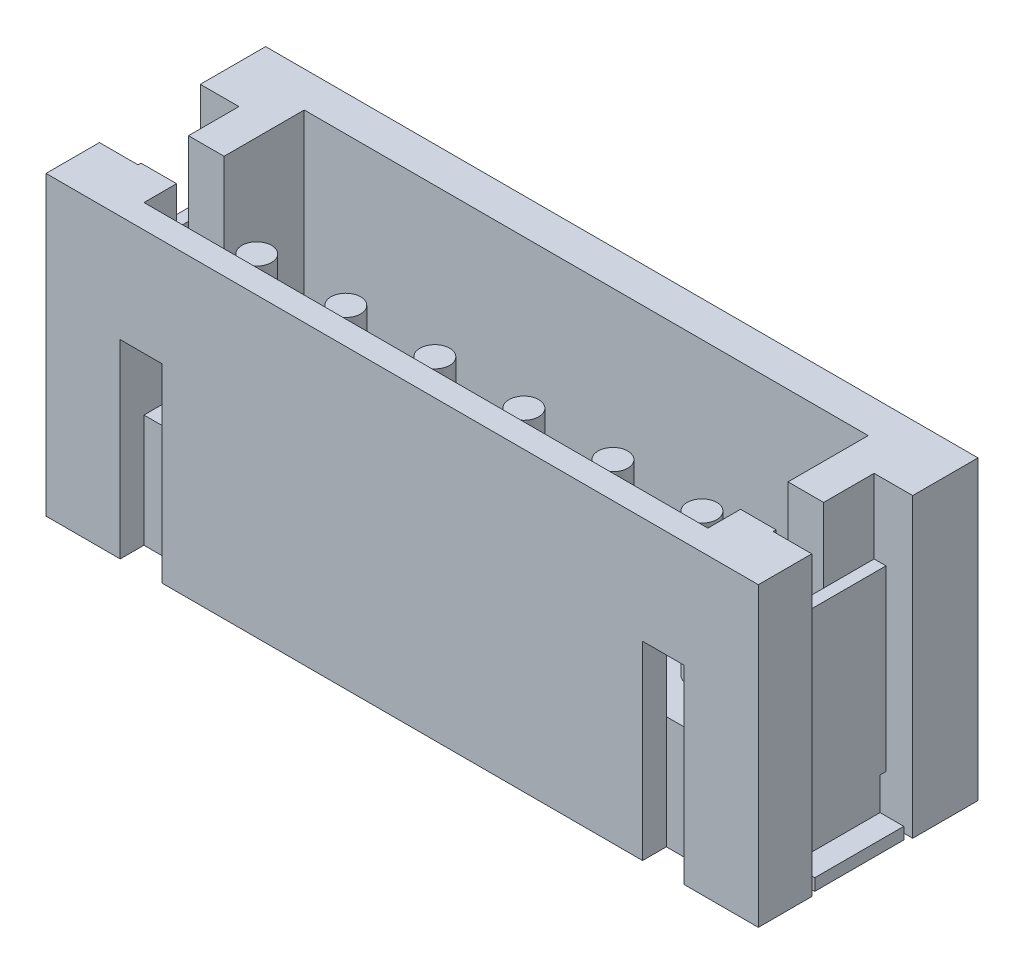
from build123d import *

# Parameters (mm, degrees)
SKETCH1_W           = 1.25
SKETCH1_H           = 5
BOSS_EXTRUDE1_DEPTH = 3.1
BOSS_EXTRUDE2_DEPTH = 9.5
BOSS_EXTRUDE3_DEPTH = 1.250000167
CUT_EXTRUDE1_DEPTH  = 0.7
CUT_EXTRUDE2_DEPTH  = 0.7
BOSS_EXTRUDE4_DEPTH = 0.6
SKETCH7_W           = 0.45
SKETCH7_H           = 1.7
CUT_EXTRUDE3_DEPTH  = 6.0000001
CUT_EXTRUDE4_REACH  = 13.55
SKETCH8_W           = 0.8
SKETCH8_H           = 1.25
SKETCH9_W           = 0.85
SKETCH9_H           = 1.25
CUT_EXTRUDE5_DEPTH  = 0.2
SKETCH10_W          = 0.05
SKETCH10_H          = 1.25
CUT_EXTRUDE6_DEPTH  = 0.2
CUT_EXTRUDE7_REACH  = 3.8
SKETCH12_W          = 0.6
SKETCH12_H          = 0.8
SKETCH13_W          = 0.45
SKETCH13_H          = 1.7
CUT_EXTRUDE8_DEPTH  = 6.0000001
SKETCH14_W          = 0.8
SKETCH14_H          = 1.25
CUT_EXTRUDE9_DEPTH  = 12.5500001
SKETCH15_W          = 0.85
SKETCH15_H          = 1.25
CUT_EXTRUDE10_DEPTH = 0.2
CUT_EXTRUDE11_REACH = 2.65
SKETCH17_W          = 0.1
SKETCH17_H          = 0.75
SKETCH18_W          = 1.5
SKETCH18_H          = 0.2
BOSS_EXTRUDE5_DEPTH = 0.4
CUT_EXTRUDE12_REACH = 2.65
SKETCH20_W          = 0.1
SKETCH20_H          = 0.75
CUT_EXTRUDE13_REACH = 2.65
SKETCH22_W          = 0.75
SKETCH22_H          = 0.1
SKETCH23_W          = 1.5
SKETCH23_H          = 0.2
BOSS_EXTRUDE6_DEPTH = 0.4
CUT_EXTRUDE14_REACH = 2.65
SKETCH25_W          = 0.75
SKETCH25_H          = 0.1
SKETCH26_W          = 0.05
SKETCH26_H          = 1.25
CUT_EXTRUDE15_DEPTH = 0.2
CUT_EXTRUDE16_REACH = 3.8
SKETCH28_W          = 0.6
SKETCH28_H          = 0.8
SKETCH29_W          = 0.25
SKETCH29_H          = 2.4
SKETCH30_W          = 0.25
SKETCH30_H          = 2.4
SKETCH31_W          = 0.25
SKETCH31_H          = 2.4
SKETCH32_W          = 0.25
SKETCH32_H          = 2.4
SKETCH33_W          = 0.25
SKETCH33_H          = 2.4
SKETCH34_W          = 0.25
SKETCH34_H          = 2.4
SKETCH35_W          = 0.25
SKETCH35_H          = 1.5
SKETCH36_W          = 0.25
SKETCH36_H          = 1.5
SKETCH37_W          = 0.25
SKETCH37_H          = 1.5
SKETCH38_W          = 0.25
SKETCH38_H          = 1.5
SKETCH39_W          = 0.25
SKETCH39_H          = 1.5
SKETCH40_W          = 0.25
SKETCH40_H          = 1.5


with BuildPart() as part:
    # Sketch1 → Boss-Extrude1 (new body)
    with BuildSketch(Plane.XY):
        with Locations((-5.375, 2.5)):
            Rectangle(SKETCH1_W, SKETCH1_H)
    extrude(amount=-BOSS_EXTRUDE1_DEPTH)

    # Sketch2 → Boss-Extrude2 (add)
    with BuildSketch(Plane(origin=(-4.75, 0, 0), x_dir=(0, 0, -1), z_dir=(1, 0, 0))):
        with BuildLine():
            Line((0, 5), (0.4, 5))
            Line((0.4, 5), (0.4, 1.9))
            Line((0.4, 1.9), (1.75, 1.9))
            Line((1.75, 1.9), (2.05, 1.6))
            Line((2.05, 1.6), (3.1, 1.6))
            add(Edge.make_bspline(
                [(3.1, 0), (3.1, 1.6)],
                knots=[0, 0, 0.32, 0.32], degree=1))
            Line((3.1, 0), (0, 0))
            Line((0, 0), (0, 5))
        make_face()
    extrude(amount=BOSS_EXTRUDE2_DEPTH)

    # Sketch3 → Boss-Extrude3 (add)
    with BuildSketch(Plane(origin=(4.75, 0, 0), x_dir=(0, 0, -1), z_dir=(1, 0, 0))):
        with BuildLine():
            Line((3.1, 0), (0, 0))
            Line((0, 0), (0, 5))
            Line((0, 5), (3.1, 5))
            add(Edge.make_bspline(
                [(3.1, 0), (3.1, 5)],
                knots=[0, 0, 1, 1], degree=1))
        make_face()
    extrude(amount=BOSS_EXTRUDE3_DEPTH)

    # Sketch4 → Cut-Extrude1 (cut)
    with BuildSketch(Plane(origin=(4.75, 0, 0), x_dir=(0, 0, -1), z_dir=(1, 0, 0))):
        Polygon((0.4, 1.9), (0.4, 3.2), (0, 3.2), (0, 0), (0.4, 0), align=None)
    extrude(amount=-CUT_EXTRUDE1_DEPTH, mode=Mode.SUBTRACT)

    # Sketch5 → Cut-Extrude2 (cut)
    with BuildSketch(Plane(origin=(-4.75, 0, 0), x_dir=(0, -1, 0), z_dir=(-1, 0, 0))):
        Polygon((-1.9, -0.4), (0, -0.4), (0, 0), (-3.2, 0), (-3.2, -0.4), align=None)
    extrude(amount=-CUT_EXTRUDE2_DEPTH, mode=Mode.SUBTRACT)

    # Sketch6 → Boss-Extrude4 (add)
    with BuildSketch(Plane(origin=(0, 0, -3.1), x_dir=(-1, 0, 0), z_dir=(0, 0, -1))):
        with BuildLine():
            add(Edge.make_bspline(
                [(6, 0), (-6, 0)],
                knots=[0, 0, 1, 1], degree=1))
            add(Edge.make_bspline(
                [(-6, 0), (-6, 5)],
                knots=[0, 0, 1, 1], degree=1))
            add(Edge.make_bspline(
                [(6, 5), (-6, 5)],
                knots=[0, 0, 1, 1], degree=1))
            add(Edge.make_bspline(
                [(6, 0), (6, 5)],
                knots=[0, 0, 1, 1], degree=1))
        make_face()
    extrude(amount=BOSS_EXTRUDE4_DEPTH)

    # Sketch7 → Cut-Extrude3 (cut, through all)
    with BuildSketch(Plane.XZ):
        with Locations((-5.775, -1.75)):
            Rectangle(SKETCH7_W, SKETCH7_H)
    extrude(amount=-CUT_EXTRUDE3_DEPTH, mode=Mode.SUBTRACT)

    # Sketch8 → Cut-Extrude4 (cut, up to next)
    with BuildSketch(Plane.ZY.offset(5.55), mode=Mode.PRIVATE) as cut_extrude4_sk1:
        with Locations((-1.35, 4.375)):
            Rectangle(SKETCH8_W, SKETCH8_H)
    cut_extrude4_tool1 = extrude(cut_extrude4_sk1.sketch, amount=-CUT_EXTRUDE4_REACH, mode=Mode.PRIVATE) & part.part
    add(cut_extrude4_tool1.solids().sort_by_distance((-5.55, 4.375, -1.35))[0], mode=Mode.SUBTRACT)

    # Sketch9 → Cut-Extrude5 (cut)
    with BuildSketch(Plane.ZY.offset(5.55)):
        with Locations((-2.175, 4.375)):
            Rectangle(SKETCH9_W, SKETCH9_H)
    extrude(amount=-CUT_EXTRUDE5_DEPTH, mode=Mode.SUBTRACT)

    # Sketch10 → Cut-Extrude6 (cut)
    with BuildSketch(Plane.ZY.offset(5.55)):
        with Locations((-0.925, 4.375)):
            Rectangle(SKETCH10_W, SKETCH10_H)
    extrude(amount=-CUT_EXTRUDE6_DEPTH, mode=Mode.SUBTRACT)

    # Sketch12 → Cut-Extrude7 (cut, up to next)
    with BuildSketch(Plane.XZ.offset(-3.2), mode=Mode.PRIVATE) as cut_extrude7_sk1:
        with Locations((-5.05, -1.35)):
            Rectangle(SKETCH12_W, SKETCH12_H)
    cut_extrude7_tool1 = extrude(cut_extrude7_sk1.sketch, amount=-CUT_EXTRUDE7_REACH, mode=Mode.PRIVATE) & part.part
    add(cut_extrude7_tool1.solids().sort_by_distance((-5.05, 3.2, -1.35))[0], mode=Mode.SUBTRACT)

    # Sketch13 → Cut-Extrude8 (cut, through all)
    with BuildSketch(Plane.XZ):
        with Locations((5.775, -1.75)):
            Rectangle(SKETCH13_W, SKETCH13_H)
    extrude(amount=-CUT_EXTRUDE8_DEPTH, mode=Mode.SUBTRACT)

    # Sketch14 → Cut-Extrude9 (cut, through all)
    with BuildSketch(Plane(origin=(5.55, 0, 0), x_dir=(0, 0, -1), z_dir=(1, 0, 0))):
        with Locations((1.35, 4.375)):
            Rectangle(SKETCH14_W, SKETCH14_H)
    extrude(amount=-CUT_EXTRUDE9_DEPTH, mode=Mode.SUBTRACT)

    # Sketch15 → Cut-Extrude10 (cut)
    with BuildSketch(Plane(origin=(5.55, 0, 0), x_dir=(0, 0, -1), z_dir=(1, 0, 0))):
        with Locations((2.175, 4.375)):
            Rectangle(SKETCH15_W, SKETCH15_H)
    extrude(amount=-CUT_EXTRUDE10_DEPTH, mode=Mode.SUBTRACT)

    # Sketch17 → Cut-Extrude11 (cut, up to next)
    with BuildSketch(Plane(origin=(-5.35, 0, 0), x_dir=(0, 0, -1), z_dir=(1, 0, 0)), mode=Mode.PRIVATE) as cut_extrude11_sk1:
        with Locations((0.95, 0.375)):
            Rectangle(SKETCH17_W, SKETCH17_H)
    cut_extrude11_tool1 = extrude(cut_extrude11_sk1.sketch, amount=-CUT_EXTRUDE11_REACH, mode=Mode.PRIVATE) & part.part
    add(cut_extrude11_tool1.solids().sort_by_distance((-5.35, 0.375, -0.95))[0], mode=Mode.SUBTRACT)

    # Sketch18 → Boss-Extrude5 (add)
    with BuildSketch(Plane.ZY.offset(5.55)):
        with Locations((-1.75, 0.1)):
            Rectangle(SKETCH18_W, SKETCH18_H)
    extrude(amount=BOSS_EXTRUDE5_DEPTH)

    # Sketch20 → Cut-Extrude12 (cut, up to next)
    with BuildSketch(Plane(origin=(-5.35, 0, 0), x_dir=(0, 0, -1), z_dir=(1, 0, 0)), mode=Mode.PRIVATE) as cut_extrude12_sk1:
        with Locations((2.55, 0.375)):
            Rectangle(SKETCH20_W, SKETCH20_H)
    cut_extrude12_tool1 = extrude(cut_extrude12_sk1.sketch, amount=-CUT_EXTRUDE12_REACH, mode=Mode.PRIVATE) & part.part
    add(cut_extrude12_tool1.solids().sort_by_distance((-5.35, 0.375, -2.55))[0], mode=Mode.SUBTRACT)

    # Sketch22 → Cut-Extrude13 (cut, up to next)
    with BuildSketch(Plane(origin=(5.35, 0, 0), x_dir=(0, -1, 0), z_dir=(-1, 0, 0)), mode=Mode.PRIVATE) as cut_extrude13_sk1:
        with Locations((-0.375, -2.55)):
            Rectangle(SKETCH22_W, SKETCH22_H)
    cut_extrude13_tool1 = extrude(cut_extrude13_sk1.sketch, amount=-CUT_EXTRUDE13_REACH, mode=Mode.PRIVATE) & part.part
    add(cut_extrude13_tool1.solids().sort_by_distance((5.35, 0.375, -2.55))[0], mode=Mode.SUBTRACT)

    # Sketch23 → Boss-Extrude6 (add)
    with BuildSketch(Plane(origin=(5.55, 0, 0), x_dir=(0, 0, -1), z_dir=(1, 0, 0))):
        with Locations((1.75, 0.1)):
            Rectangle(SKETCH23_W, SKETCH23_H)
    extrude(amount=BOSS_EXTRUDE6_DEPTH)

    # Sketch25 → Cut-Extrude14 (cut, up to next)
    with BuildSketch(Plane(origin=(5.35, 0, 0), x_dir=(0, -1, 0), z_dir=(-1, 0, 0)), mode=Mode.PRIVATE) as cut_extrude14_sk1:
        with Locations((-0.375, -0.95)):
            Rectangle(SKETCH25_W, SKETCH25_H)
    cut_extrude14_tool1 = extrude(cut_extrude14_sk1.sketch, amount=-CUT_EXTRUDE14_REACH, mode=Mode.PRIVATE) & part.part
    add(cut_extrude14_tool1.solids().sort_by_distance((5.35, 0.375, -0.95))[0], mode=Mode.SUBTRACT)

    # Sketch26 → Cut-Extrude15 (cut)
    with BuildSketch(Plane(origin=(5.55, 0, 0), x_dir=(0, 0, -1), z_dir=(1, 0, 0))):
        with Locations((0.925, 4.375)):
            Rectangle(SKETCH26_W, SKETCH26_H)
    extrude(amount=-CUT_EXTRUDE15_DEPTH, mode=Mode.SUBTRACT)

    # Sketch28 → Cut-Extrude16 (cut, up to next)
    with BuildSketch(Plane.XZ.offset(-3.2), mode=Mode.PRIVATE) as cut_extrude16_sk1:
        with Locations((5.05, -1.35)):
            Rectangle(SKETCH28_W, SKETCH28_H)
    cut_extrude16_tool1 = extrude(cut_extrude16_sk1.sketch, amount=-CUT_EXTRUDE16_REACH, mode=Mode.PRIVATE) & part.part
    add(cut_extrude16_tool1.solids().sort_by_distance((5.05, 3.2, -1.35))[0], mode=Mode.SUBTRACT)

    # Sketch29 → Revolve1 (revolve)
    with BuildSketch(Plane(origin=(0, 0, -1.3), x_dir=(-1, 0, 0), z_dir=(0, 0, -1))):
        with Locations((-3.875, 3.1)):
            Rectangle(SKETCH29_W, SKETCH29_H)
    revolve(axis=Axis((3.75, 1.9, -1.3), (0, 1, 0)))

    # Sketch30 → Revolve2 (revolve)
    with BuildSketch(Plane(origin=(0, 0, -1.3), x_dir=(-1, 0, 0), z_dir=(0, 0, -1))):
        with Locations((-2.375, 3.1)):
            Rectangle(SKETCH30_W, SKETCH30_H)
    revolve(axis=Axis((2.25, 1.9, -1.3), (0, 1, 0)))

    # Sketch31 → Revolve3 (revolve)
    with BuildSketch(Plane(origin=(0, 0, -1.3), x_dir=(-1, 0, 0), z_dir=(0, 0, -1))):
        with Locations((-0.875, 3.1)):
            Rectangle(SKETCH31_W, SKETCH31_H)
    revolve(axis=Axis((0.75, 1.9, -1.3), (0, 1, 0)))

    # Sketch32 → Revolve4 (revolve)
    with BuildSketch(Plane(origin=(0, 0, -1.3), x_dir=(-1, 0, 0), z_dir=(0, 0, -1))):
        with Locations((0.625, 3.1)):
            Rectangle(SKETCH32_W, SKETCH32_H)
    revolve(axis=Axis((-0.75, 1.9, -1.3), (0, 1, 0)))

    # Sketch33 → Revolve5 (revolve)
    with BuildSketch(Plane(origin=(0, 0, -1.3), x_dir=(-1, 0, 0), z_dir=(0, 0, -1))):
        with Locations((2.125, 3.1)):
            Rectangle(SKETCH33_W, SKETCH33_H)
    revolve(axis=Axis((-2.25, 1.9, -1.3), (0, 1, 0)))

    # Sketch34 → Revolve6 (revolve)
    with BuildSketch(Plane(origin=(0, 0, -1.3), x_dir=(-1, 0, 0), z_dir=(0, 0, -1))):
        with Locations((3.625, 3.1)):
            Rectangle(SKETCH34_W, SKETCH34_H)
    revolve(axis=Axis((-3.75, 1.9, -1.3), (0, 1, 0)))

    # Sketch35 → Revolve7 (revolve)
    with BuildSketch(Plane.XZ.offset(-0.25)):
        with Locations((3.875, -4.45)):
            Rectangle(SKETCH35_W, SKETCH35_H)
    revolve(axis=Axis((3.75, 0.25, -3.7), (0, 0, -1)))

    # Sketch36 → Revolve8 (revolve)
    with BuildSketch(Plane.XZ.offset(-0.25)):
        with Locations((2.375, -4.45)):
            Rectangle(SKETCH36_W, SKETCH36_H)
    revolve(axis=Axis((2.25, 0.25, -3.7), (0, 0, -1)))

    # Sketch37 → Revolve9 (revolve)
    with BuildSketch(Plane.XZ.offset(-0.25)):
        with Locations((0.875, -4.45)):
            Rectangle(SKETCH37_W, SKETCH37_H)
    revolve(axis=Axis((0.75, 0.25, -3.7), (0, 0, -1)))

    # Sketch38 → Revolve10 (revolve)
    with BuildSketch(Plane.XZ.offset(-0.25)):
        with Locations((-0.625, -4.45)):
            Rectangle(SKETCH38_W, SKETCH38_H)
    revolve(axis=Axis((-0.75, 0.25, -3.7), (0, 0, -1)))

    # Sketch39 → Revolve11 (revolve)
    with BuildSketch(Plane.XZ.offset(-0.25)):
        with Locations((-2.125, -4.45)):
            Rectangle(SKETCH39_W, SKETCH39_H)
    revolve(axis=Axis((-2.25, 0.25, -3.7), (0, 0, -1)))

    # Sketch40 → Revolve12 (revolve)
    with BuildSketch(Plane.XZ.offset(-0.25)):
        with Locations((-3.625, -4.45)):
            Rectangle(SKETCH40_W, SKETCH40_H)
    revolve(axis=Axis((-3.75, 0.25, -3.7), (0, 0, -1)))


solid = part.part
